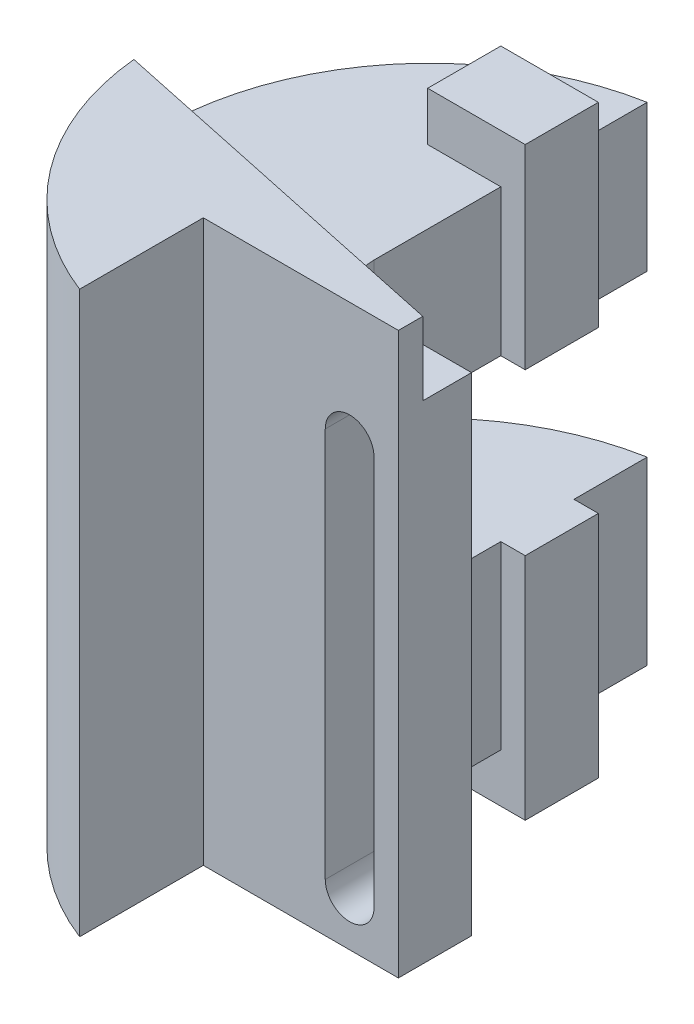
from build123d import *

# Parameters (mm, degrees)
BOSS_EXTRUDE1_DEPTH = 100
BOSS_EXTRUDE2_DEPTH = 15
SKETCH3_W           = 20
SKETCH3_H           = 15
BOSS_EXTRUDE3_DEPTH = 60
SKETCH4_W           = 40
SKETCH4_H           = 33
CUT_EXTRUDE1_DEPTH  = 119.5
CUT_EXTRUDE2_DEPTH  = 119.5


with BuildPart() as part:
    # Sketch1 → Boss-Extrude1 (new body)
    with BuildSketch(Plane(origin=(0, 0, 0), x_dir=(1, 0, 0), z_dir=(0, 1, 0))):
        with BuildLine():
            Line((0, 0), (0, 15))
            Line((0, 15), (-20, 15))
            ThreePointArc((-20, 15), (-27.071067812, 17.928932188), (-30, 25))
            Line((-30, 25), (-30, 81))
            ThreePointArc((-30, 81), (-75.256322222, 31.603413808), (-40, -25.362796982))
            Line((-40, -25.362796982), (-40, 0))
            Line((-40, 0), (0, 0))
        make_face()
    extrude(amount=BOSS_EXTRUDE1_DEPTH)

    # Sketch2 → Boss-Extrude2 (add)
    with BuildSketch(Plane(origin=(0, 100, 0), x_dir=(1, 0, 0), z_dir=(0, 1, 0))):
        with BuildLine():
            Line((0, 5), (-75.235044142, 20.9917023))
            ThreePointArc((-75.235044142, 20.9917023), (-64.184418834, -7.177185713), (-40, -25.362796982))
            Line((-40, -25.362796982), (-40, 0))
            Line((-40, 0), (0, 0))
            Line((0, 0), (0, 5))
        make_face()
    extrude(amount=BOSS_EXTRUDE2_DEPTH)

    # Sketch3 → Boss-Extrude3 (add, symmetric)
    with BuildSketch(Plane(origin=(0, 50, 0), x_dir=(1, 0, 0), z_dir=(0, 1, 0))):
        with Locations((-35, 58.5)):
            Rectangle(SKETCH3_W, SKETCH3_H)
    extrude(amount=BOSS_EXTRUDE3_DEPTH, both=True)

    # Sketch4 → Cut-Extrude1 (cut, symmetric)
    with BuildSketch(Plane(origin=(0, 0, 0), x_dir=(0, 0, -1), z_dir=(1, 0, 0))):
        with Locations((61, 53.5)):
            Rectangle(SKETCH4_W, SKETCH4_H)
    extrude(amount=CUT_EXTRUDE1_DEPTH, both=True, mode=Mode.SUBTRACT)

    # Sketch5 → Cut-Extrude2 (cut, symmetric)
    with BuildSketch(Plane(origin=(0, 0, -15), x_dir=(-1, 0, 0), z_dir=(0, 0, -1))):
        with BuildLine():
            Line((15, 90), (15, 10))
            ThreePointArc((15, 10), (10, 5), (5, 10))
            Line((5, 10), (5, 90))
            ThreePointArc((5, 90), (10, 95), (15, 90))
        make_face()
    extrude(amount=CUT_EXTRUDE2_DEPTH, both=True, mode=Mode.SUBTRACT)


solid = part.part
